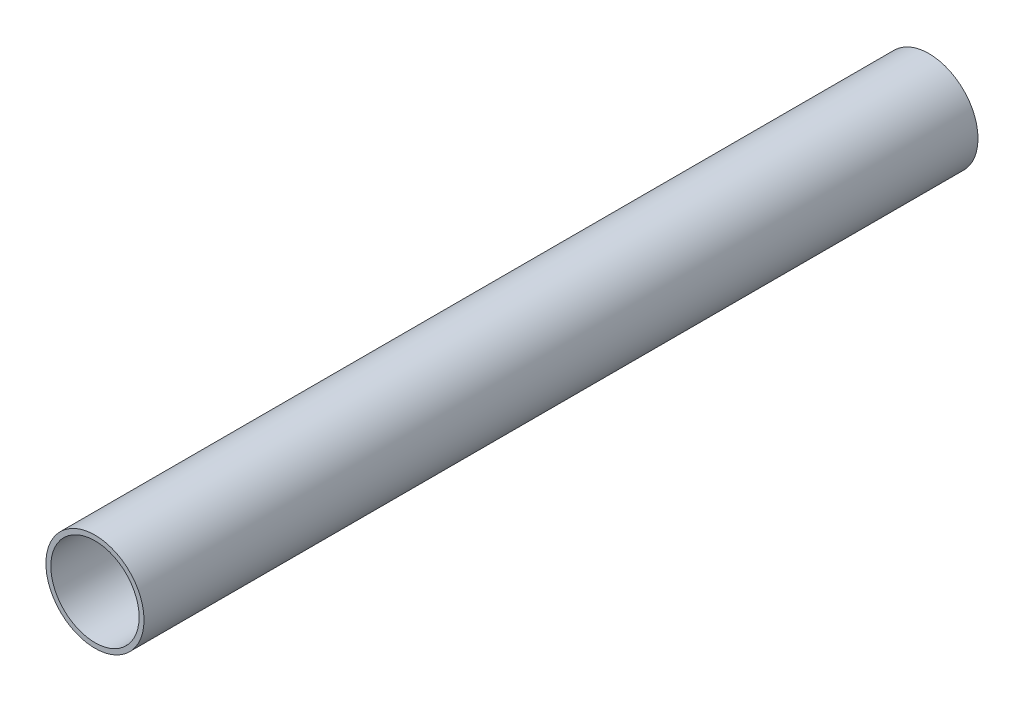
from build123d import *

# Parameters (mm, degrees)
SKETCH3_R           = 10
SKETCH3_R_2         = 9
EXTRUDE_THIN2_DEPTH = 170


with BuildPart() as part:
    # Sketch3 → Extrude-Thin2 (new body)
    with BuildSketch(Plane.XY):
        Circle(SKETCH3_R)
        Circle(SKETCH3_R_2, mode=Mode.SUBTRACT)
    extrude(amount=EXTRUDE_THIN2_DEPTH)


solid = part.part
